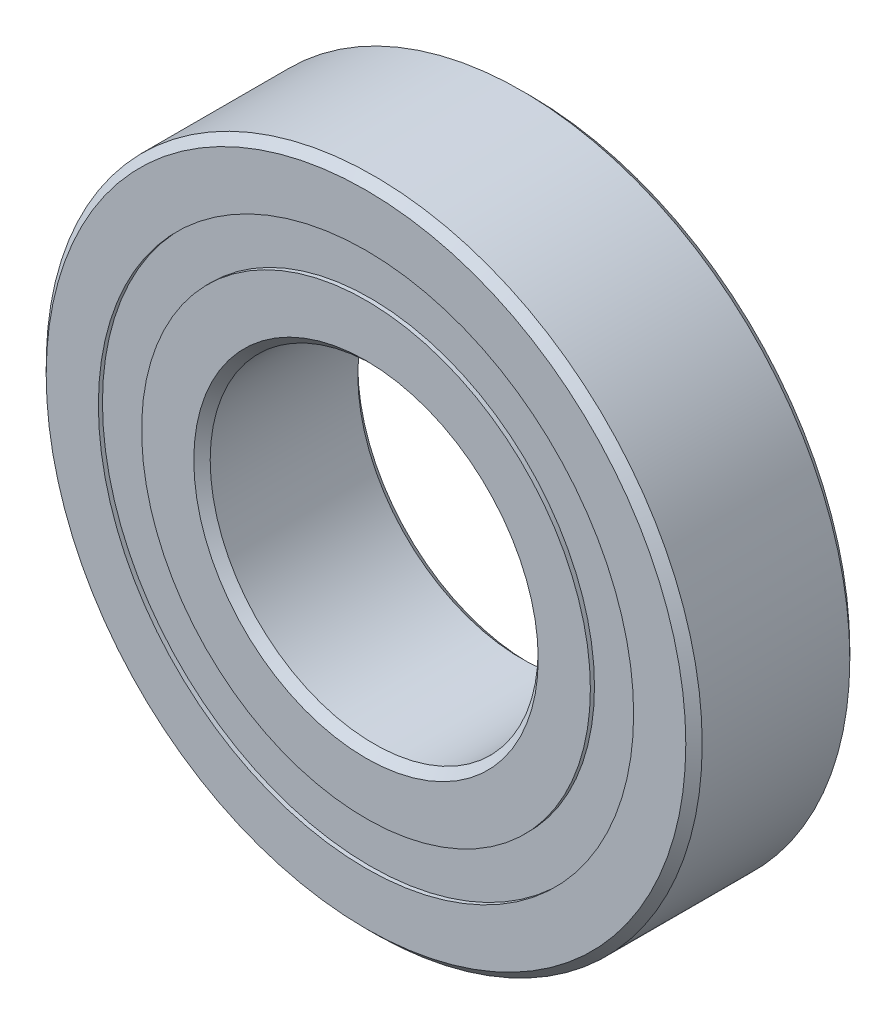
from build123d import *

# Parameters (mm, degrees)
CIRPATTERN1_COUNT = 12
SKETCH5_W         = 2.750786573
SKETCH5_H         = 3.34945055


with BuildPart() as part:
    # Sketch1 → Revolve1 (revolve)
    with BuildSketch(Plane(origin=(0, 0, 0), x_dir=(0, 0, -1), z_dir=(1, 0, 0))):
        with BuildLine():
            Line((5.715, 25.4), (-5.715, 25.4))
            Line((-5.715, 25.4), (-6.35, 24.765))
            Line((-6.35, 24.765), (-6.35, 20.724725275))
            Line((-6.35, 20.724725275), (-2.822222222, 20.724725275))
            ThreePointArc((-2.822222222, 20.724725275), (0, 22.331713427), (2.822222222, 20.724725275))
            Line((2.822222222, 20.724725275), (6.35, 20.724725275))
            Line((6.35, 20.724725275), (6.35, 24.765))
            Line((6.35, 24.765), (5.715, 25.4))
        make_face()
    revolve(axis=Axis((0, 0, 6.35), (0, 0, -1)))


with BuildPart() as body_2:
    # Sketch3 → Revolve3 (revolve)
    with BuildSketch(Plane(origin=(0, 0, 0), x_dir=(0, 0, -1), z_dir=(1, 0, 0))):
        with BuildLine():
            Line((-6.35, 17.375274725), (-2.822222222, 17.375274725))
            ThreePointArc((-2.822222222, 17.375274725), (0, 15.768286573), (2.822222222, 17.375274725))
            Line((2.822222222, 17.375274725), (6.35, 17.375274725))
            Line((6.35, 17.375274725), (6.35, 13.335))
            Line((6.35, 13.335), (5.715, 12.7))
            Line((5.715, 12.7), (-5.715, 12.7))
            Line((-5.715, 12.7), (-6.35, 13.335))
            Line((-6.35, 13.335), (-6.35, 17.375274725))
        make_face()
    revolve(axis=Axis((0, 0, 6.35), (0, 0, -1)))


with BuildPart() as body_3:
    # Sketch4 → Revolve4 (revolve)
    with BuildSketch(Plane(origin=(0, 0, 0), x_dir=(0, 0, -1), z_dir=(1, 0, 0))):
        with BuildLine():
            Line((-3.281713427, 19.05), (3.281713427, 19.05))
            ThreePointArc((3.281713427, 19.05), (0, 22.331713427), (-3.281713427, 19.05))
        make_face()
    revolve(axis=Axis((0, 19.05, 3.281713427), (0, 0, -1)))


with BuildPart() as cirpattern1_1:
    # CirPattern1: pattern copy
    add(body_3.part.rotate(Axis((0, 0, 0), (0, 0, 1)), 1 * 360 / CIRPATTERN1_COUNT))


with BuildPart() as cirpattern1_2:
    # CirPattern1: pattern copy
    add(body_3.part.rotate(Axis((0, 0, 0), (0, 0, 1)), 2 * 360 / CIRPATTERN1_COUNT))


with BuildPart() as cirpattern1_3:
    # CirPattern1: pattern copy
    add(body_3.part.rotate(Axis((0, 0, 0), (0, 0, 1)), 3 * 360 / CIRPATTERN1_COUNT))


with BuildPart() as cirpattern1_4:
    # CirPattern1: pattern copy
    add(body_3.part.rotate(Axis((0, 0, 0), (0, 0, 1)), 4 * 360 / CIRPATTERN1_COUNT))


with BuildPart() as cirpattern1_5:
    # CirPattern1: pattern copy
    add(body_3.part.rotate(Axis((0, 0, 0), (0, 0, 1)), 5 * 360 / CIRPATTERN1_COUNT))


with BuildPart() as cirpattern1_6:
    # CirPattern1: pattern copy
    add(body_3.part.rotate(Axis((0, 0, 0), (0, 0, 1)), 6 * 360 / CIRPATTERN1_COUNT))


with BuildPart() as cirpattern1_7:
    # CirPattern1: pattern copy
    add(body_3.part.rotate(Axis((0, 0, 0), (0, 0, 1)), 7 * 360 / CIRPATTERN1_COUNT))


with BuildPart() as cirpattern1_8:
    # CirPattern1: pattern copy
    add(body_3.part.rotate(Axis((0, 0, 0), (0, 0, 1)), 8 * 360 / CIRPATTERN1_COUNT))


with BuildPart() as cirpattern1_9:
    # CirPattern1: pattern copy
    add(body_3.part.rotate(Axis((0, 0, 0), (0, 0, 1)), 9 * 360 / CIRPATTERN1_COUNT))


with BuildPart() as cirpattern1_10:
    # CirPattern1: pattern copy
    add(body_3.part.rotate(Axis((0, 0, 0), (0, 0, 1)), 10 * 360 / CIRPATTERN1_COUNT))


with BuildPart() as cirpattern1_11:
    # CirPattern1: pattern copy
    add(body_3.part.rotate(Axis((0, 0, 0), (0, 0, 1)), 11 * 360 / CIRPATTERN1_COUNT))


with BuildPart() as body_15:
    # Sketch5 → Revolve5 (revolve)
    with BuildSketch(Plane(origin=(0, 0, 0), x_dir=(0, 0, -1), z_dir=(1, 0, 0))):
        with Locations((-4.657106714, 19.05)):
            Rectangle(SKETCH5_W, SKETCH5_H)
        with Locations((4.657106714, 19.05)):
            Rectangle(SKETCH5_W, SKETCH5_H)
    revolve(axis=Axis((0, 0, 6.35), (0, 0, -1)))


solid = Compound([part.part, body_2.part, body_3.part, cirpattern1_1.part, cirpattern1_2.part, cirpattern1_3.part, cirpattern1_4.part, cirpattern1_5.part, cirpattern1_6.part, cirpattern1_7.part, cirpattern1_8.part, cirpattern1_9.part, cirpattern1_10.part, cirpattern1_11.part, body_15.part])
